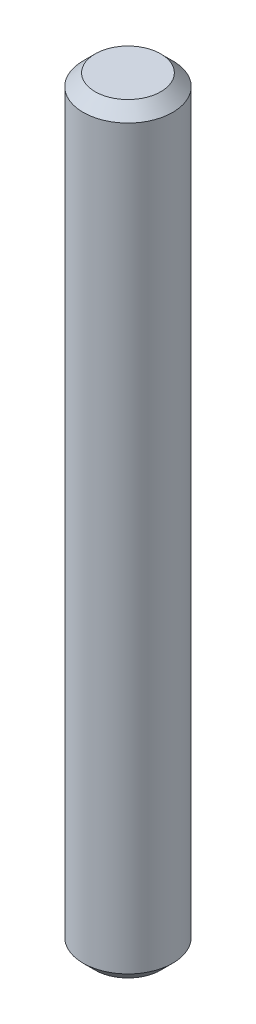
from build123d import *

# Parameters (mm, degrees)
SKETCH1_R           = 1.5
BOSS_EXTRUDE1_DEPTH = 12.75
CHAMFER1_SIZE       = 0.4


with BuildPart() as part:
    # Sketch1 → Boss-Extrude1 (new body, symmetric)
    with BuildSketch(Plane(origin=(0, 0, 0), x_dir=(1, 0, 0), z_dir=(0, 1, 0))):
        Circle(SKETCH1_R)
    extrude(amount=BOSS_EXTRUDE1_DEPTH, both=True)

    # Chamfer1
    chamfer1_edges = [part.edges().sort_by_distance(p)[0] for p in [
        (-1.5, -12.75, 0),
        (-1.5, 12.75, 0),
    ]]
    chamfer(chamfer1_edges, length=CHAMFER1_SIZE)


solid = part.part
